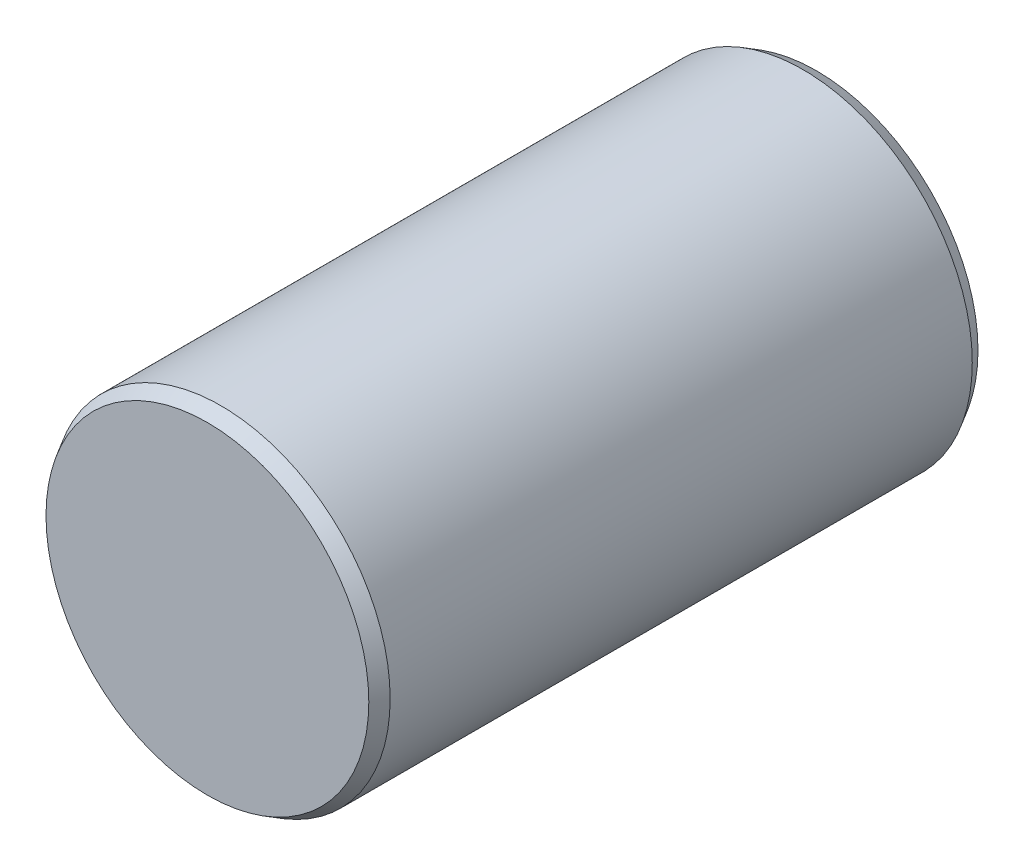
from build123d import *

# Parameters (mm, degrees)
ESQUISSE1_R        = 2.5
BOSS_EXTRU_1_DEPTH = 4.5
CHANFREIN1_SIZE    = 0.2
CHANFREIN1_SIZE2   = 0.115470054


with BuildPart() as part:
    # Esquisse1 → Boss.-Extru.1 (new body, symmetric)
    with BuildSketch(Plane.XY):
        Circle(ESQUISSE1_R)
    extrude(amount=BOSS_EXTRU_1_DEPTH, both=True)

    # Chanfrein1
    chanfrein1_edges = [part.edges().sort_by_distance(p)[0] for p in [
        (-2.5, 0, -4.5),
        (-2.5, 0, 4.5),
    ]]
    chanfrein1_side = [part.faces().sort_by_distance(p)[0] for p in [
        (-2.5, 0, 0),
    ]]
    chamfer(chanfrein1_edges, length=CHANFREIN1_SIZE, length2=CHANFREIN1_SIZE2, reference=chanfrein1_side[0])


solid = part.part
